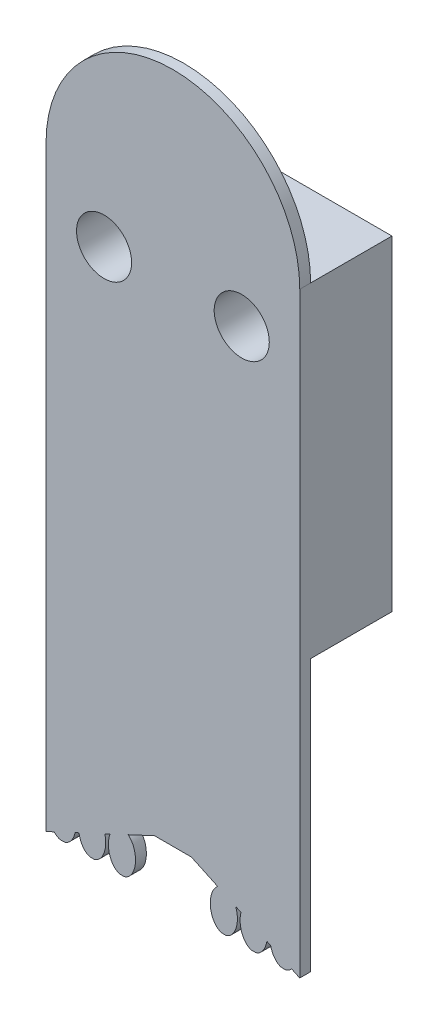
from build123d import *

# Parameters (mm, degrees)
SKETCH1_W           = 46.787939469
SKETCH1_H           = 60
SKETCH1_R           = 5.08
BOSS_EXTRUDE1_DEPTH = 15
SKETCH2_W           = 46.787939469
SKETCH2_H           = 60
SKETCH2_R           = 5.08
BOSS_EXTRUDE2_DEPTH = 2


with BuildPart() as part:
    # Sketch1 → Boss-Extrude1 (new body)
    with BuildSketch(Plane.XY):
        with Locations((-102.767623853, -313.368909969)):
            Rectangle(SKETCH1_W, SKETCH1_H)
        with Locations((-90.073654119, -294.630909969)):
            Circle(SKETCH1_R, mode=Mode.SUBTRACT)
        with Locations((-115.461593588, -294.630909969)):
            Circle(SKETCH1_R, mode=Mode.SUBTRACT)
    extrude(amount=BOSS_EXTRUDE1_DEPTH)

    # Sketch2 → Boss-Extrude2 (add)
    with BuildSketch(Plane.XY.offset(15)):
        with BuildLine():
            Line((-79.373654119, -343.368909969), (-102.767623854, -343.368909969))
            Line((-102.767623854, -343.368909969), (-102.767623854, -384.042756806))
            Line((-102.767623854, -384.042756806), (-99.373654119, -384.042756806))
            Line((-99.373654119, -384.042756806), (-94.503579918, -386.313709702))
            add(Edge.make_bspline(
                [(-94.503579918, -386.313709702), (-100.00398624, -390.494082743), (-94.115799531, -393.239789298), (-93.929989905, -393.32643375), (-93.73748043, -393.368909969)],
                knots=[0.468972903, 0.468972903, 0.468972903, 2.84019184, 2.84019184, 3.029420352, 3.029420352, 3.029420352], degree=2, weights=[1, 0.37573231, 1, 0.950182059, 0.908315281]))
            Line((-93.73748043, -393.368909969), (-93.009827808, -393.368909969))
            add(Edge.make_bspline(
                [(-93.009827808, -393.368909969), (-89.462741956, -392.586263836), (-91.178526324, -387.864207656)],
                knots=[3.345008297, 3.345008297, 3.345008297, 5.211410777, 5.211410777, 5.211410777], degree=2, weights=[0.790783298, 0.508634675, 1]))
            Line((-91.178526324, -387.864207656), (-90.208062599, -388.316742323))
            add(Edge.make_bspline(
                [(-90.208062599, -388.316742323), (-91.162547167, -392.052221372), (-88.615799531, -393.239789298), (-88.429989905, -393.32643375), (-88.23748043, -393.368909969)],
                knots=[1.204788076, 1.204788076, 1.204788076, 2.84019184, 2.84019184, 3.008967996, 3.008967996, 3.008967996], degree=2, weights=[1, 0.683899664, 1, 0.967377965, 0.941489216]))
            Line((-88.23748043, -393.368909969), (-87.509827808, -393.368909969))
            add(Edge.make_bspline(
                [(-87.509827808, -393.368909969), (-85.839475159, -393.000355303), (-85.443416113, -390.538533468)],
                knots=[3.304458938, 3.304458938, 3.304458938, 4.475595603, 4.475595603, 4.475595603], degree=2, weights=[0.871477119, 0.773635905, 1]))
            Line((-85.443416113, -390.538533468), (-84.740509949, -390.866303995))
            add(Edge.make_bspline(
                [(-84.740509949, -390.866303995), (-84.248679529, -393.03547171), (-82.73748043, -393.368909969)],
                knots=[1.898629299, 1.898629299, 1.898629299, 2.984182814, 2.984182814, 2.984182814], degree=2, weights=[1, 0.762799808, 0.799074283]))
            Line((-82.73748043, -393.368909969), (-82.009827808, -393.368909969))
            add(Edge.make_bspline(
                [(-82.009827808, -393.368909969), (-81.386018968, -393.231269777), (-80.880341234, -392.666330229)],
                knots=[3.261132643, 3.261132643, 3.261132643, 3.781754381, 3.781754381, 3.781754381], degree=2, weights=[0.83538307, 0.886240914, 1]))
            Line((-80.880341234, -392.666330229), (-79.373654119, -393.368909969))
            Line((-79.373654119, -393.368909969), (-79.373654119, -343.368909969))
        make_face()
        with BuildLine():
            Line((-126.161593588, -343.368909969), (-126.161593588, -393.368909969))
            Line((-126.161593588, -393.368909969), (-124.654906474, -392.666330229))
            add(Edge.make_bspline(
                [(-124.654906474, -392.666330229), (-124.14922874, -393.231269777), (-123.525419899, -393.368909969)],
                knots=[2.501430927, 2.501430927, 2.501430927, 3.022052664, 3.022052664, 3.022052664], degree=2, weights=[1, 0.886240914, 0.83538307]))
            Line((-123.525419899, -393.368909969), (-122.797767278, -393.368909969))
            add(Edge.make_bspline(
                [(-122.797767278, -393.368909969), (-121.286568178, -393.03547171), (-120.794737759, -390.866303995)],
                knots=[3.299002493, 3.299002493, 3.299002493, 4.384556008, 4.384556008, 4.384556008], degree=2, weights=[0.799074283, 0.762799808, 1]))
            Line((-120.794737759, -390.866303995), (-120.091831594, -390.538533468))
            add(Edge.make_bspline(
                [(-120.091831594, -390.538533468), (-119.695772548, -393.000355303), (-118.025419899, -393.368909969)],
                knots=[1.807589704, 1.807589704, 1.807589704, 2.97872637, 2.97872637, 2.97872637], degree=2, weights=[1, 0.773635905, 0.871477119]))
            Line((-118.025419899, -393.368909969), (-117.297767278, -393.368909969))
            add(Edge.make_bspline(
                [(-117.297767278, -393.368909969), (-117.105257803, -393.32643375), (-116.919448176, -393.239789298), (-114.37270054, -392.052221372), (-115.327185108, -388.316742323)],
                knots=[3.274217312, 3.274217312, 3.274217312, 3.442993467, 3.442993467, 5.078397231, 5.078397231, 5.078397231], degree=2, weights=[0.941489216, 0.967377965, 1, 0.683899664, 1]))
            Line((-115.327185108, -388.316742323), (-114.356721383, -387.864207656))
            add(Edge.make_bspline(
                [(-114.356721383, -387.864207656), (-116.072505751, -392.586263836), (-112.525419899, -393.368909969)],
                knots=[1.071774531, 1.071774531, 1.071774531, 2.93817701, 2.93817701, 2.93817701], degree=2, weights=[1, 0.508634675, 0.790783298]))
            Line((-112.525419899, -393.368909969), (-111.797767278, -393.368909969))
            add(Edge.make_bspline(
                [(-111.797767278, -393.368909969), (-111.605257803, -393.32643375), (-111.419448176, -393.239789298), (-105.531261468, -390.494082743), (-111.031667789, -386.313709702)],
                knots=[3.253764955, 3.253764955, 3.253764955, 3.442993467, 3.442993467, 5.814212404, 5.814212404, 5.814212404], degree=2, weights=[0.908315281, 0.950182059, 1, 0.37573231, 1]))
            Line((-111.031667789, -386.313709702), (-106.161593588, -384.042756806))
            Line((-106.161593588, -384.042756806), (-102.767623854, -384.042756806))
            Line((-102.767623854, -384.042756806), (-102.767623854, -343.368909969))
            Line((-102.767623854, -343.368909969), (-126.161593588, -343.368909969))
        make_face()
        with Locations((-102.767623853, -313.368909969)):
            Rectangle(SKETCH2_W, SKETCH2_H)
        with Locations((-115.461593588, -294.630909969)):
            Circle(SKETCH2_R, mode=Mode.SUBTRACT)
        with Locations((-90.073654119, -294.630909969)):
            Circle(SKETCH2_R, mode=Mode.SUBTRACT)
        with BuildLine():
            ThreePointArc((-79.373654119, -283.368909969), (-102.767623854, -259.974940234), (-126.161593588, -283.368909969))
            Line((-126.161593588, -283.368909969), (-79.373654119, -283.368909969))
        make_face()
    extrude(amount=BOSS_EXTRUDE2_DEPTH)


solid = part.part
